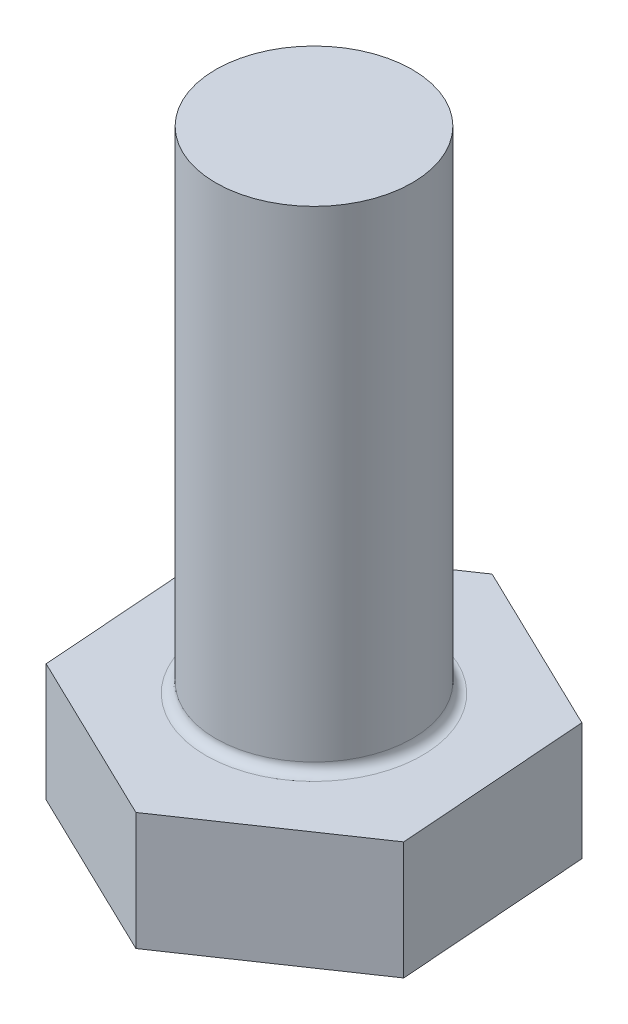
from build123d import *

# Parameters (mm, degrees)
SZKIC1_R                    = 5
DODANIE_WYCI_GNI_CIE1_DEPTH = 25
DODANIE_WYCI_GNI_CIE2_DEPTH = 6
ZAOKR_GLENIE1_R             = 0.5


with BuildPart() as part:
    # Szkic1 → Dodanie-wyciągnięcie1 (new body)
    with BuildSketch(Plane(origin=(0, 0, 0), x_dir=(1, 0, 0), z_dir=(0, 1, 0))):
        Circle(SZKIC1_R)
    extrude(amount=DODANIE_WYCI_GNI_CIE1_DEPTH)

    # Szkic2 → Dodanie-wyciągnięcie2 (add)
    with BuildSketch(Plane(origin=(0, 0, 0), x_dir=(-1, 0, 0), z_dir=(0, -1, 0))):
        Polygon((-0.721110691, -9.78842851), (8.116472407, -5.518714433), (8.837583099, 4.269714077), (0.721110691, 9.78842851), (-8.116472407, 5.518714433), (-8.837583099, -4.269714077), align=None)
    extrude(amount=DODANIE_WYCI_GNI_CIE2_DEPTH)

    # Zaokrąglenie1
    zaokr_glenie1_edges = [part.edges().sort_by_distance(p)[0] for p in [
        (-5, 0, 0),
    ]]
    fillet(zaokr_glenie1_edges, radius=ZAOKR_GLENIE1_R)


solid = part.part
